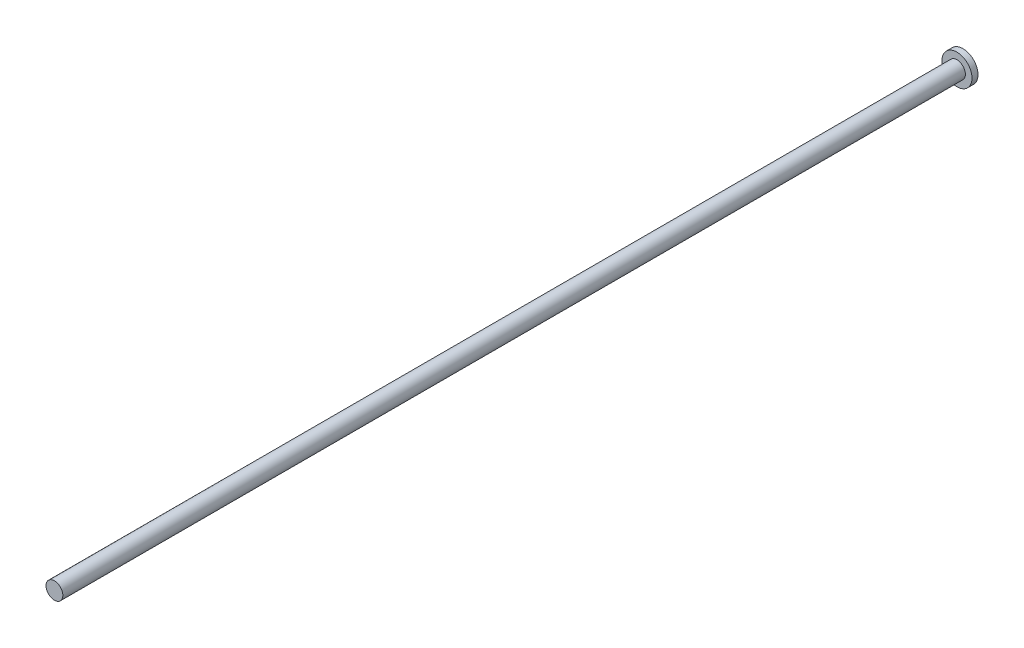
from build123d import *

# Parameters (mm, degrees)
SKETCH2_R           = 2.5
BOSS_EXTRUDE1_DEPTH = 1
SKETCH3_R           = 1.4
BOSS_EXTRUDE2_DEPTH = 150


with BuildPart() as part:
    # Sketch2 → Boss-Extrude1 (new body)
    with BuildSketch(Plane.XY):
        Circle(SKETCH2_R)
    extrude(amount=BOSS_EXTRUDE1_DEPTH)

    # Sketch3 → Boss-Extrude2 (add)
    with BuildSketch(Plane.XY.offset(1)):
        Circle(SKETCH3_R)
    extrude(amount=BOSS_EXTRUDE2_DEPTH)


solid = part.part
